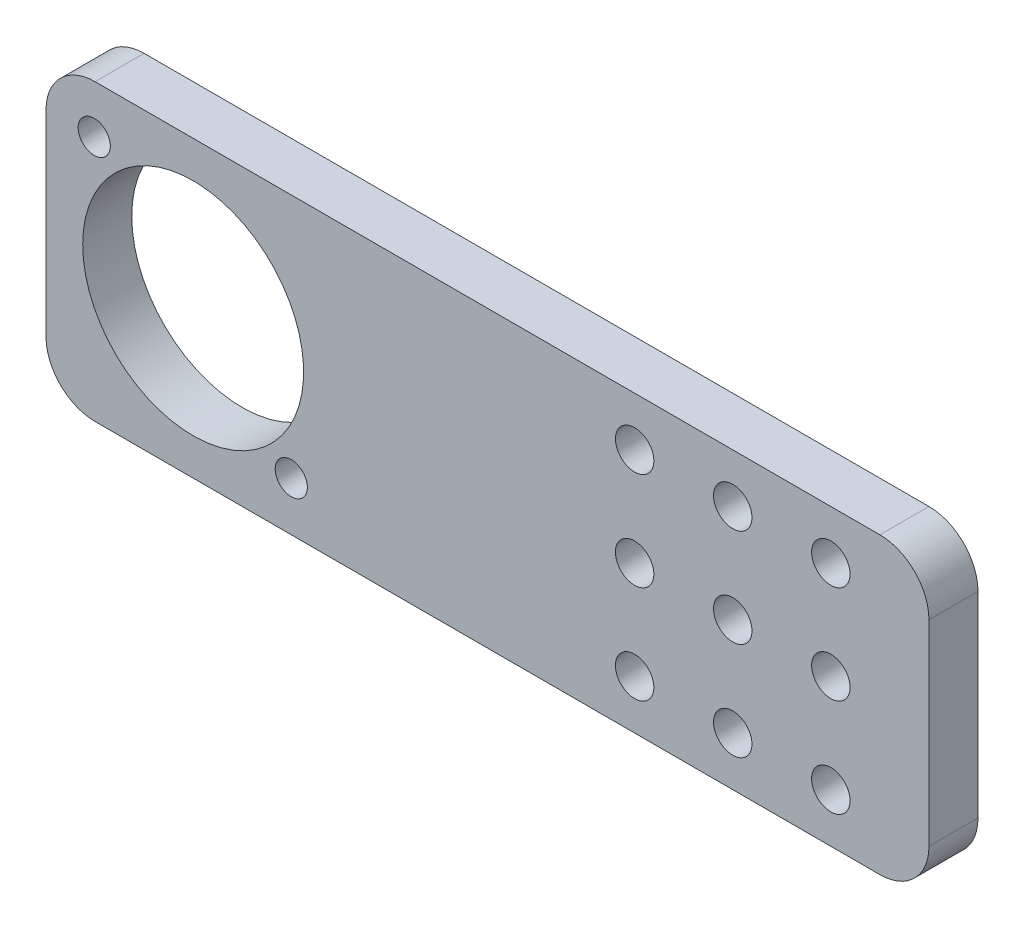
from build123d import *

# Parameters (mm, degrees)
SKETCH1_R           = 14.3002
SKETCH1_R_2         = 2.0828
SKETCH1_R_3         = 2.4892
BOSS_EXTRUDE1_DEPTH = 6.35


with BuildPart() as part:
    # Sketch1 → Boss-Extrude1 (new body)
    with BuildSketch(Plane.XY):
        with BuildLine():
            Line((114.3, -12.7), (114.3, 12.7))
            ThreePointArc((114.3, 12.7), (112.440128061, 17.190128061), (107.95, 19.05))
            Line((107.95, 19.05), (6.35, 19.05))
            ThreePointArc((6.35, 19.05), (1.859871939, 17.190128061), (0, 12.7))
            Line((0, 12.7), (0, -12.7))
            ThreePointArc((0, -12.7), (1.859871939, -17.190128061), (6.35, -19.05))
            Line((6.35, -19.05), (107.95, -19.05))
            ThreePointArc((107.95, -19.05), (112.440128061, -17.190128061), (114.3, -12.7))
        make_face()
        with Locations((19.05, 0)):
            Circle(SKETCH1_R, mode=Mode.SUBTRACT)
        with Locations((6.244154771, 12.805845229)):
            Circle(SKETCH1_R_2, mode=Mode.SUBTRACT)
        with Locations((31.75, -12.7)):
            Circle(SKETCH1_R_2, mode=Mode.SUBTRACT)
        with Locations((88.9, 12.7)):
            Circle(SKETCH1_R_3, mode=Mode.SUBTRACT)
        with Locations((101.6, 12.7)):
            Circle(SKETCH1_R_3, mode=Mode.SUBTRACT)
        with Locations((88.9, 0)):
            Circle(SKETCH1_R_3, mode=Mode.SUBTRACT)
        with Locations((101.6, 0)):
            Circle(SKETCH1_R_3, mode=Mode.SUBTRACT)
        with Locations((88.9, -12.7)):
            Circle(SKETCH1_R_3, mode=Mode.SUBTRACT)
        with Locations((76.2, 12.7)):
            Circle(SKETCH1_R_3, mode=Mode.SUBTRACT)
        with Locations((101.6, -12.7)):
            Circle(SKETCH1_R_3, mode=Mode.SUBTRACT)
        with Locations((76.2, 0)):
            Circle(SKETCH1_R_3, mode=Mode.SUBTRACT)
        with Locations((76.2, -12.7)):
            Circle(SKETCH1_R_3, mode=Mode.SUBTRACT)
    extrude(amount=-BOSS_EXTRUDE1_DEPTH)


solid = part.part
